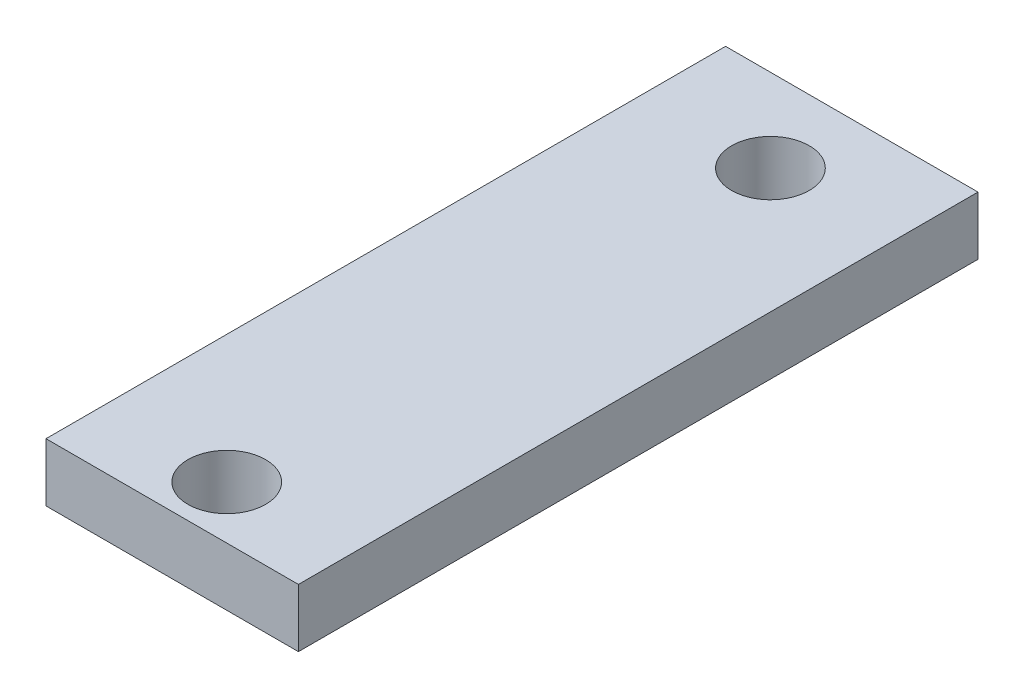
from build123d import *

# Parameters (mm, degrees)
SKETCH2_W           = 13
SKETCH2_H           = 35
SKETCH2_R           = 2
BOSS_EXTRUDE1_DEPTH = 3


with BuildPart() as part:
    # Sketch2 → Boss-Extrude1 (new body)
    with BuildSketch(Plane(origin=(0, 0, 0), x_dir=(1, 0, 0), z_dir=(0, 1, 0))):
        with Locations((75.088422911, 36.627576326)):
            Rectangle(SKETCH2_W, SKETCH2_H)
        with Locations((75.175119765, 49.850190154)):
            Circle(SKETCH2_R, mode=Mode.SUBTRACT)
        with Locations((75.175119765, 21.850190154)):
            Circle(SKETCH2_R, mode=Mode.SUBTRACT)
    extrude(amount=BOSS_EXTRUDE1_DEPTH)


solid = part.part
